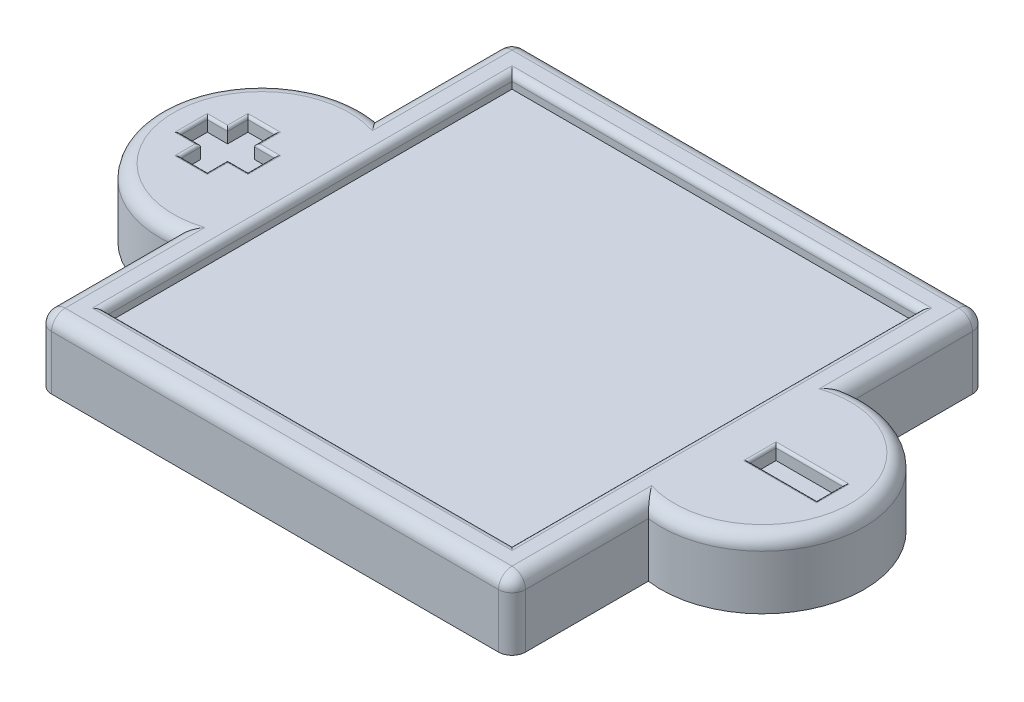
from build123d import *

# Parameters (mm, degrees)
SKETCH1_R           = 19.05
SKETCH1_W           = 88.9
SKETCH1_H           = 88.9
BOSS_EXTRUDE1_DEPTH = 12.7
SKETCH2_W           = 76.2
SKETCH2_H           = 76.2
CUT_EXTRUDE1_DEPTH  = 2.54
SKETCH3_W           = 5.08
SKETCH3_H           = 3.81
SKETCH3_W_2         = 3.81
SKETCH3_H_2         = 5.08
SKETCH3_W_3         = 12.7
CUT_EXTRUDE2_DEPTH  = 2.54
SKETCH4_R           = 3.5
CUT_EXTRUDE4_DEPTH  = 5
FILLET8_R           = 0.508
FILLET9_R           = 2.54
FILLET10_R          = 0.508
FILLET11_R          = 1.27


with BuildPart() as part:
    # Sketch1 → Boss-Extrude1 (new body)
    with BuildSketch(Plane(origin=(0, 0, 0), x_dir=(1, 0, 0), z_dir=(0, 1, 0))):
        with BuildLine():
            ThreePointArc((-35.674486373, -7.268553459), (-40.384167339, 5.271691754), (-52.184486373, 11.61135385))
            Line((-52.184486373, 11.61135385), (-52.184486373, -26.148460768))
            ThreePointArc((-52.184486373, -26.148460768), (-40.384167339, -19.808798672), (-35.674486373, -7.268553459))
        make_face()
        with BuildLine():
            Line((-52.184486373, -26.148460768), (-52.184486373, 11.61135385))
            ThreePointArc((-52.184486373, 11.61135385), (-73.774486373, -7.268553459), (-52.184486373, -26.148460768))
        make_face()
        with Locations((39.255513627, -7.268553459)):
            Circle(SKETCH1_R)
        with Locations((-54.724486373, -7.268553459)):
            Circle(SKETCH1_R)
        with Locations((-7.734486373, -7.268553459)):
            Rectangle(SKETCH1_W, SKETCH1_H)
        with BuildLine():
            ThreePointArc((58.305513627, -7.268553459), (51.79575884, 7.071765575), (36.715513627, 11.61135385))
            Line((36.715513627, 11.61135385), (36.715513627, -26.148460768))
            ThreePointArc((36.715513627, -26.148460768), (51.79575884, -21.608872493), (58.305513627, -7.268553459))
        make_face()
        with BuildLine():
            Line((36.715513627, -26.148460768), (36.715513627, 11.61135385))
            ThreePointArc((36.715513627, 11.61135385), (20.205513627, -7.268553459), (36.715513627, -26.148460768))
        make_face()
    extrude(amount=BOSS_EXTRUDE1_DEPTH)

    # Sketch2 → Cut-Extrude1 (cut)
    with BuildSketch(Plane(origin=(0, 12.7, 0), x_dir=(1, 0, 0), z_dir=(0, 1, 0))):
        with Locations((-7.734486373, -7.268553459)):
            Rectangle(SKETCH2_W, SKETCH2_H)
    extrude(amount=-CUT_EXTRUDE1_DEPTH, mode=Mode.SUBTRACT)

    # Sketch3 → Cut-Extrude2 (cut)
    with BuildSketch(Plane(origin=(0, 12.7, 0), x_dir=(1, 0, 0), z_dir=(0, 1, 0))):
        with Locations((-61.074486373, -2.823553459)):
            Rectangle(SKETCH3_W, SKETCH3_H)
        with Locations((-65.519486373, -7.268553459)):
            Rectangle(SKETCH3_W_2, SKETCH3_H_2)
        with Locations((-61.074486373, -7.268553459)):
            Rectangle(SKETCH3_W, SKETCH3_H_2)
        with Locations((-56.629486373, -7.268553459)):
            Rectangle(SKETCH3_W_2, SKETCH3_H_2)
        with Locations((-61.074486373, -11.713553459)):
            Rectangle(SKETCH3_W, SKETCH3_H)
        with Locations((45.605513627, -7.268553459)):
            Rectangle(SKETCH3_W_3, SKETCH3_H_2)
    extrude(amount=-CUT_EXTRUDE2_DEPTH, mode=Mode.SUBTRACT)

    # Sketch4 → Cut-Extrude4 (cut)
    with BuildSketch(Plane.XZ):
        with Locations((-29.959486373, 7.268553459)):
            Circle(SKETCH4_R)
        with Locations((14.490513627, 7.268553459)):
            Circle(SKETCH4_R)
    extrude(amount=-CUT_EXTRUDE4_DEPTH, mode=Mode.SUBTRACT)

    # Fillet8
    fillet8_edges = [part.edges().sort_by_distance(p)[0] for p in [
        (-33.459486373, 0, 7.268553459),
        (10.990513627, 0, 7.268553459),
    ]]
    fillet(fillet8_edges, radius=FILLET8_R)

    # Fillet9
    fillet9_edges = [part.edges().sort_by_distance(p)[0] for p in [
        (-7.734486373, 12.7, 51.718553459),
        (-52.184486373, 6.35, -37.181446541),
        (36.715513627, 6.35, -37.181446541),
        (36.715513627, 6.35, 51.718553459),
        (-52.184486373, 6.35, 51.718553459),
        (36.715513627, 12.7, 38.933507114),
        (58.305513627, 12.7, 7.268553459),
        (36.715513627, 12.7, -24.396400195),
        (-7.734486373, 12.7, -37.181446541),
        (-52.184486373, 12.7, -24.396400195),
        (-73.774486373, 12.7, 7.268553459),
        (-52.184486373, 12.7, 38.933507114),
    ]]
    fillet(fillet9_edges, radius=FILLET9_R)

    # Fillet10
    fillet10_edges = [part.edges().sort_by_distance(p)[0] for p in [
        (-63.614486373, 12.7, 2.823553459),
        (-61.074486373, 12.7, 0.918553459),
        (-54.724486373, 12.7, 7.268553459),
        (-56.629486373, 12.7, 9.808553459),
        (-63.614486373, 12.7, 11.713553459),
        (-65.519486373, 12.7, 9.808553459),
        (-65.519486373, 12.7, 4.728553459),
        (-67.424486373, 12.7, 7.268553459),
        (-61.074486373, 12.7, 13.618553459),
        (-58.534486373, 12.7, 11.713553459),
        (-56.629486373, 12.7, 4.728553459),
        (-58.534486373, 12.7, 2.823553459),
        (51.955513627, 12.7, 7.268553459),
        (45.605513627, 12.7, 4.728553459),
        (39.255513627, 12.7, 7.268553459),
        (45.605513627, 12.7, 9.808553459),
    ]]
    fillet(fillet10_edges, radius=FILLET10_R)

    # Fillet11
    fillet11_edges = [part.edges().sort_by_distance(p)[0] for p in [
        (-45.834486373, 12.7, 7.268553459),
        (-7.734486373, 12.7, 45.368553459),
        (30.365513627, 12.7, 7.268553459),
        (-7.734486373, 12.7, -30.831446541),
    ]]
    fillet(fillet11_edges, radius=FILLET11_R)


solid = part.part
